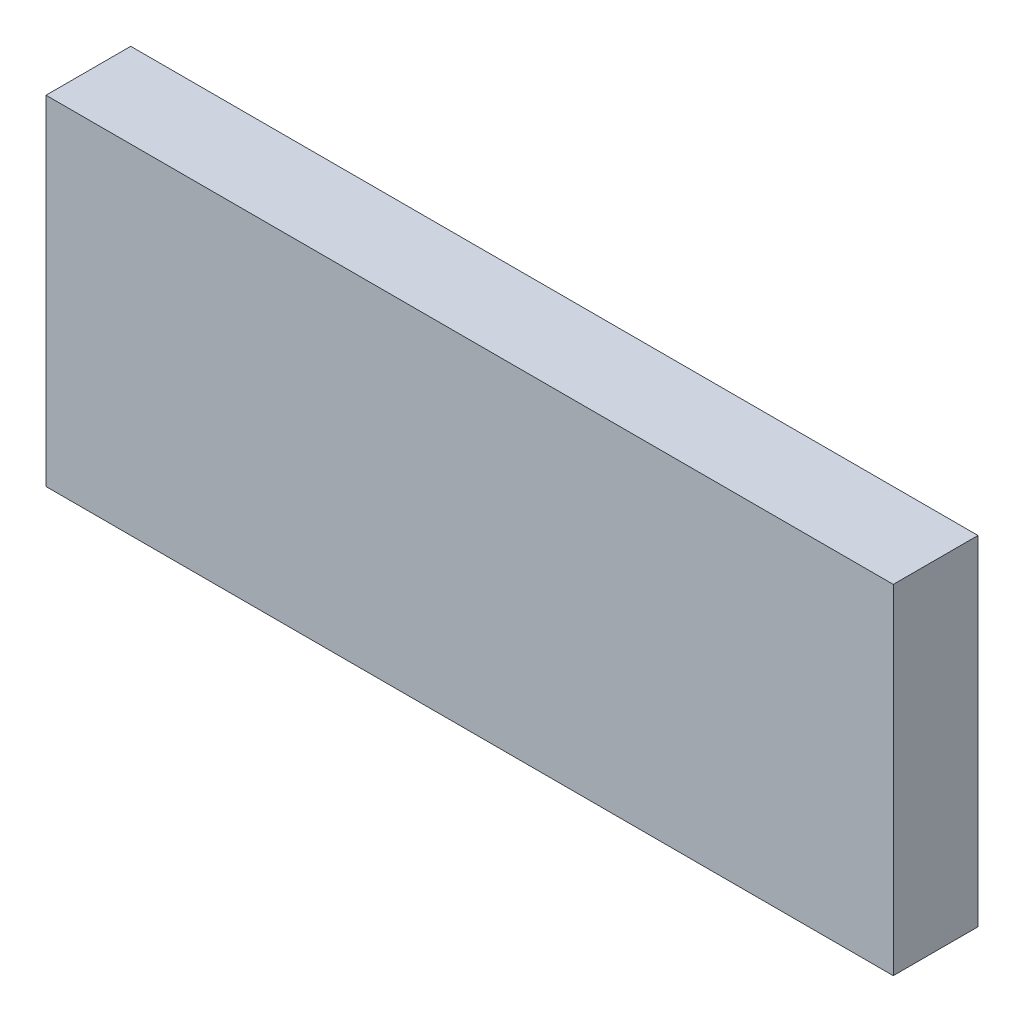
from build123d import *

# Parameters (mm, degrees)
SKETCH1_W           = 100
SKETCH1_H           = 40
BOSS_EXTRUDE1_DEPTH = 10


with BuildPart() as part:
    # Sketch1 → Boss-Extrude1 (new body)
    with BuildSketch(Plane.XY):
        Rectangle(SKETCH1_W, SKETCH1_H)
    extrude(amount=BOSS_EXTRUDE1_DEPTH)


solid = part.part
